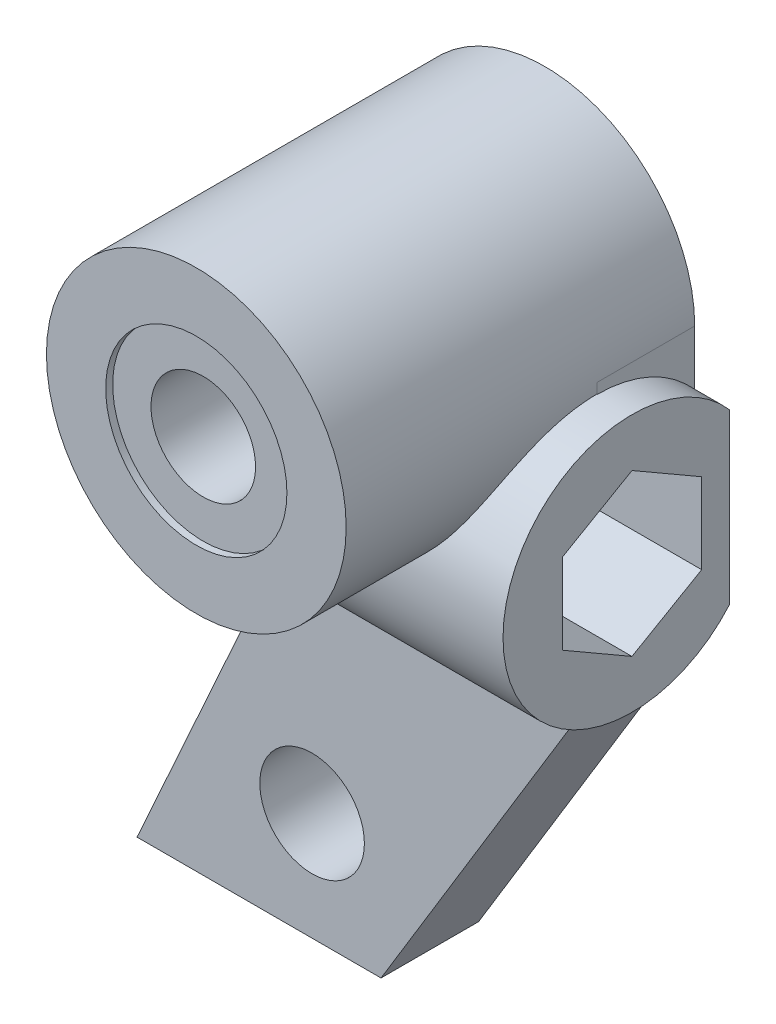
from build123d import *
from build123d.topology import SkipClean

# Parameters (mm, degrees)
SKETCH_1_R          = 1.5
EXTRUDE_1_DEPTH     = 2.8
SKETCH_3_R          = 4.3
SKETCH_3_R_2        = 1.5
EXTRUDE_4_DEPTH     = 10
CUT_EXTRUDE_START   = -0.2
SKETCH_4_R          = 2.6
SKETCH_4_R_2        = 1.5
CUT_EXTRUDE_1_DEPTH = 0.2
EXTRUDE_8_DEPTH     = 9.6
CUT_EXTRUDE_2_DEPTH = 7
SKETCH_19_R         = 1.5
CUT_EXTRUDE_3_DEPTH = 23.64000892
SKETCH_1_4_R        = 1.5
CUT_EXTRUDE_4_DEPTH = 23.352181146


with BuildPart() as part:
    # 草图1 → 凸台-拉伸1 (new body)
    with BuildSketch(Plane.XY):
        with BuildLine():
            Line((4.3, -7.7), (4.3, 0))
            ThreePointArc((4.3, 0), (0, 4.3), (-4.3, 0))
            Line((-4.3, 0), (-4.3, -7.7))
            Line((-4.3, -7.7), (-8.9, -17.9))
            Line((-8.9, -17.9), (-1.9, -17.9))
            Line((-1.9, -17.9), (4.3, -7.7))
        make_face()
        Circle(SKETCH_1_R, mode=Mode.SUBTRACT)
        with Locations((-3.877494661, -14.8)):
            Circle(SKETCH_1_R, mode=Mode.SUBTRACT)
    extrude(amount=EXTRUDE_1_DEPTH)

    # 草图3 → 凸台-拉伸4 (add)
    with SkipClean():  # the faces are left unmerged after this step: merging them gives an invalid solid
        with BuildSketch(Plane(origin=(0, 0, 0), x_dir=(-1, 0, 0), z_dir=(0, 0, -1))):
            Circle(SKETCH_3_R)
            Circle(SKETCH_3_R_2, mode=Mode.SUBTRACT)
        extrude(amount=-EXTRUDE_4_DEPTH)

    # 草图4 → 切除-拉伸1 (cut)
    with SkipClean():  # the faces are left unmerged after this step: merging them gives an invalid solid
        with BuildSketch(Plane.XY.offset(10).offset(CUT_EXTRUDE_START)):
            Circle(SKETCH_4_R)
            Circle(SKETCH_4_R_2, mode=Mode.SUBTRACT)
        extrude(amount=CUT_EXTRUDE_1_DEPTH, mode=Mode.SUBTRACT)

    # 草图17 → 凸台-拉伸8 (add)
    with SkipClean():  # the faces are left unmerged after this step: merging them gives an invalid solid
        with BuildSketch(Plane.ZY.offset(4.3)):
            with BuildLine():
                Line((0, -1.581322676), (0, -6.418677324))
                ThreePointArc((0, -6.418677324), (6.5, -4), (0, -1.581322676))
            make_face()
        extrude(amount=-EXTRUDE_8_DEPTH)

    # 草图18 → 切除-拉伸2 (cut)
    with SkipClean():  # the faces are left unmerged after this step: merging them gives an invalid solid
        with BuildSketch(Plane(origin=(5.3, 0, 0), x_dir=(0, 0, -1), z_dir=(1, 0, 0))):
            Polygon((-0.8, -5.154700538), (-0.8, -2.845299462), (-2.8, -1.690598923), (-4.8, -2.845299462), (-4.8, -5.154700538), (-2.8, -6.309401077), align=None)
        extrude(amount=-CUT_EXTRUDE_2_DEPTH, mode=Mode.SUBTRACT)

    # 草图19 → 切除-拉伸3 (cut, through all)
    with SkipClean():  # the faces are left unmerged after this step: merging them gives an invalid solid
        with BuildSketch(Plane.ZY.offset(4.3)):
            with Locations((2.8, -4)):
                Circle(SKETCH_19_R)
        extrude(amount=-CUT_EXTRUDE_3_DEPTH, mode=Mode.SUBTRACT)

    # 草图1<4> → 切除-拉伸4 (cut, through all)
    with SkipClean():  # the faces are left unmerged after this step: merging them gives an invalid solid
        with BuildSketch(Plane.XY):
            Circle(SKETCH_1_4_R)
        extrude(amount=CUT_EXTRUDE_4_DEPTH, mode=Mode.SUBTRACT)


solid = part.part
